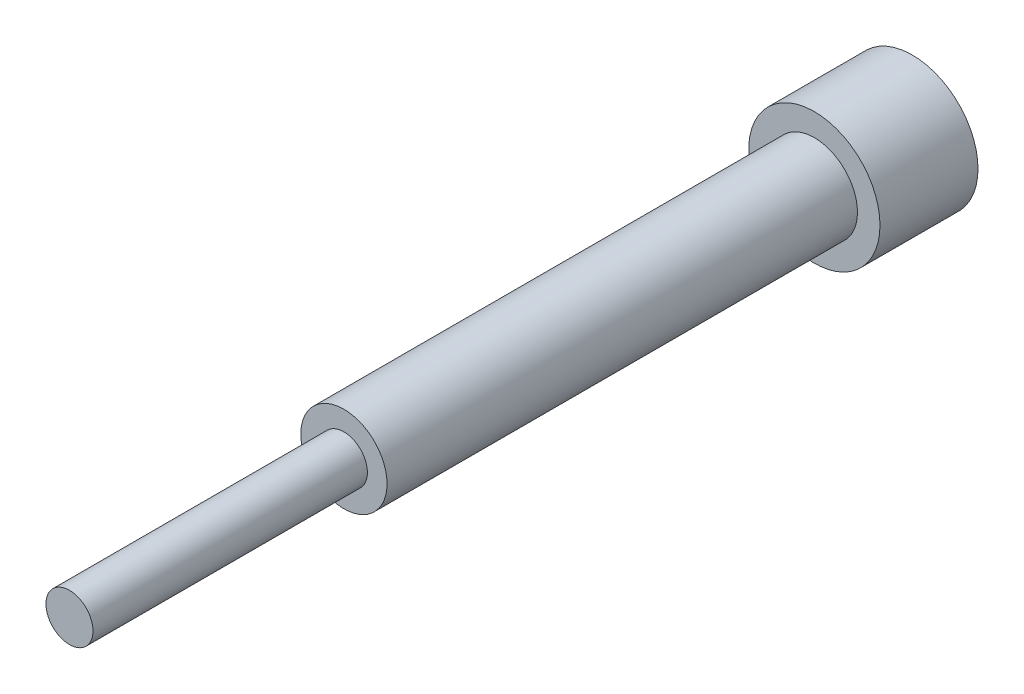
from build123d import *

# Parameters (mm, degrees)
CROQUIS1_R              = 16.75
SALIENTE_EXTRUIR1_DEPTH = 25
CROQUIS2_R              = 11
SALIENTE_EXTRUIR3_DEPTH = 120
CROQUIS3_R              = 6
SALIENTE_EXTRUIR4_DEPTH = 70


with BuildPart() as part:
    # Croquis1 → Saliente-Extruir1 (new body)
    with BuildSketch(Plane.XY):
        Circle(CROQUIS1_R)
    extrude(amount=SALIENTE_EXTRUIR1_DEPTH)

    # Croquis2 → Saliente-Extruir3 (add)
    with BuildSketch(Plane.XY.offset(25)):
        Circle(CROQUIS2_R)
    extrude(amount=SALIENTE_EXTRUIR3_DEPTH)

    # Croquis3 → Saliente-Extruir4 (add)
    with BuildSketch(Plane.XY.offset(145)):
        Circle(CROQUIS3_R)
    extrude(amount=SALIENTE_EXTRUIR4_DEPTH)


solid = part.part
